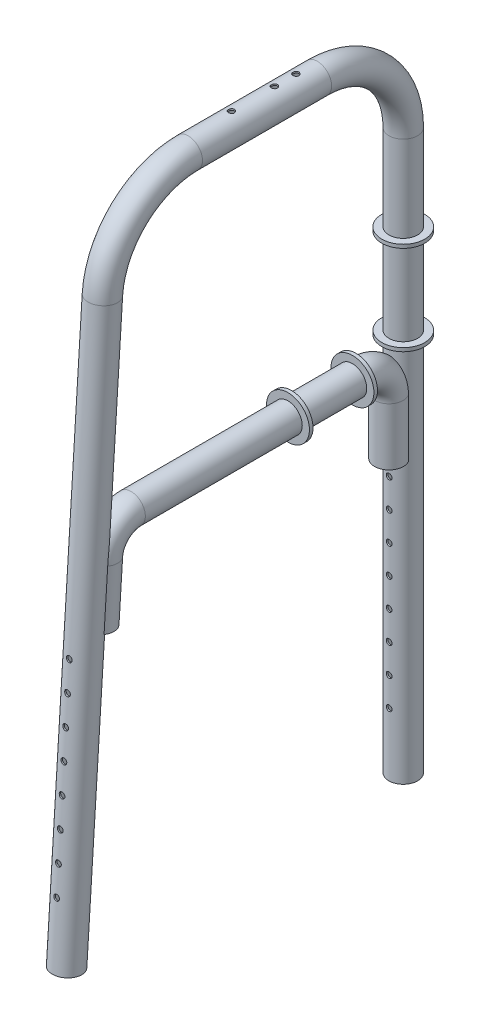
from build123d import *

# Parameters (mm, degrees)
SKETCH40_R           = 19.99999999999999
SKETCH40_R_2         = 17.99999999999999
SKETCH45_R           = 20
SKETCH45_R_2         = 18.000000000000004
CUT_SWEEP1_PROFILE_R = 20
CUT_EXTRUDE1_REACH   = 957.457
SKETCH22_R           = 4.000000000000002
SKETCH59_W           = 10
SKETCH59_H           = 5
SKETCH66_W           = 5
SKETCH66_H           = 10
SKETCH71_R           = 4.200000000000001
SKETCH71_R_2         = 4.2
SKETCH71_R_3         = 4.199999999999999
CUT_EXTRUDE3_DEPTH   = 40
SKETCH73_R           = 4.000000000000001
CUT_EXTRUDE4_DEPTH   = 1026.5520028632297


with BuildPart() as part:
    # Sweep2: sweep along a path in Sketch1
    with BuildLine(Plane(origin=(0, 0, 0), x_dir=(0, 0, -1), z_dir=(1, 0, 0))) as sweep2_path:
        Line((-237.13540242038945, 0), (-187.13540242038937, 787.6027487983755))
        ThreePointArc((-187.13540242038937, 787.6027487983755), (-149.49734187871428, 867.4995138723783), (-67.3764853799084, 900))
        Line((-67.3764853799084, 900), (112.86459757961059, 900))
        ThreePointArc((112.86459757961059, 900), (197.71741132199628, 864.8528137423857), (232.86459757961057, 780))
        Line((232.86459757961057, 780), (232.86459757961057, 0))
    # Sketch40 → Sweep2 (sweep)
    with BuildSketch(Plane(origin=(0, 0, 237.13540242038948), x_dir=(1, 0, 0), z_dir=(0, 0.9979909753373415, -0.06335623998646216))):
        Circle(SKETCH40_R)
        Circle(SKETCH40_R_2, mode=Mode.SUBTRACT)
    sweep(path=sweep2_path.line)


with BuildPart() as body_2:
    # Sweep3: sweep along a path in Sketch15
    with BuildLine(Plane(origin=(0, 0, 0), x_dir=(0, 0, -1), z_dir=(1, 0, 0))) as sweep3_path:
        Line((-192.17558291364261, 392.53424959945824), (-187.09688047627466, 472.5342495994585))
        ThreePointArc((-187.09688047627466, 472.5342495994585), (-174.55086029571626, 499.1665046241261), (-147.17724146278098, 510))
        Line((-147.17724146278098, 510), (172.86459757961066, 510.0000000000001))
        ThreePointArc((172.86459757961066, 510.0000000000001), (201.14886882707256, 498.28427124746196), (212.86459757961066, 470.00000000000006))
        Line((212.86459757961066, 470.00000000000006), (212.86459757961066, 390))
    # Sketch45 → Sweep3 (sweep)
    with BuildSketch(Plane(origin=(0, 392.5342495994583, 192.17558291364267), x_dir=(1, 0, 0), z_dir=(0, 0.9979909753373414, -0.06335623998646218))):
        Circle(SKETCH45_R)
        Circle(SKETCH45_R_2, mode=Mode.SUBTRACT)
    sweep(path=sweep3_path.line)

    # Cut-Sweep1: sweep along a path in Sketch1_3
    with BuildLine(Plane(origin=(0, 0, 0), x_dir=(0, 0, -1), z_dir=(1, 0, 0))) as cut_sweep1_path:
        Line((-237.13540242038945, 0), (-187.13540242038937, 787.6027487983755))
        ThreePointArc((-187.13540242038937, 787.6027487983755), (-149.49734187871428, 867.4995138723783), (-67.3764853799084, 900))
        Line((-67.3764853799084, 900), (112.86459757961059, 900))
        ThreePointArc((112.86459757961059, 900), (197.71741132199628, 864.8528137423857), (232.86459757961057, 780))
        Line((232.86459757961057, 780), (232.86459757961057, 0))
    # Cut-Sweep1 profile (on start of the path) → Cut-Sweep1 (sweep, cut)
    with BuildSketch(Plane(origin=(0, 0, 237.13540242038945), x_dir=(0, 0.06335623998646217, 0.9979909753373414), z_dir=(0, 0.9979909753373414, -0.06335623998646217))):
        Circle(CUT_SWEEP1_PROFILE_R)
    sweep(path=cut_sweep1_path.line, mode=Mode.SUBTRACT)


with BuildPart() as part_1:
    add(part.part)

    # Combine1: union body 2
    add(body_2.part)

    # Sketch22 → Cut-Extrude1 (cut, up to next)
    with BuildSketch(Plane.XY, mode=Mode.PRIVATE) as cut_extrude1_sk1:
        with Locations((-2.9157e-12, 367.9999999999999)):
            Circle(SKETCH22_R)
    cut_extrude1_tool1 = extrude(cut_extrude1_sk1.sketch, amount=-CUT_EXTRUDE1_REACH, mode=Mode.PRIVATE) & part_1.part
    # Sketch22 → Cut-Extrude1 (cut, up to next)
    with BuildSketch(Plane.XY, mode=Mode.PRIVATE) as cut_extrude1_sk2:
        with Locations((-2.49917e-12, 327.9999999999999)):
            Circle(SKETCH22_R)
    cut_extrude1_tool2 = extrude(cut_extrude1_sk2.sketch, amount=-CUT_EXTRUDE1_REACH, mode=Mode.PRIVATE) & part_1.part
    # Sketch22 → Cut-Extrude1 (cut, up to next)
    with BuildSketch(Plane.XY, mode=Mode.PRIVATE) as cut_extrude1_sk3:
        with Locations((-2.08264e-12, 287.99999999999994)):
            Circle(SKETCH22_R)
    cut_extrude1_tool3 = extrude(cut_extrude1_sk3.sketch, amount=-CUT_EXTRUDE1_REACH, mode=Mode.PRIVATE) & part_1.part
    # Sketch22 → Cut-Extrude1 (cut, up to next)
    with BuildSketch(Plane.XY, mode=Mode.PRIVATE) as cut_extrude1_sk4:
        with Locations((-1.66611e-12, 247.99999999999994)):
            Circle(SKETCH22_R)
    cut_extrude1_tool4 = extrude(cut_extrude1_sk4.sketch, amount=-CUT_EXTRUDE1_REACH, mode=Mode.PRIVATE) & part_1.part
    # Sketch22 → Cut-Extrude1 (cut, up to next)
    with BuildSketch(Plane.XY, mode=Mode.PRIVATE) as cut_extrude1_sk5:
        with Locations((-1.24959e-12, 207.99999999999997)):
            Circle(SKETCH22_R)
    cut_extrude1_tool5 = extrude(cut_extrude1_sk5.sketch, amount=-CUT_EXTRUDE1_REACH, mode=Mode.PRIVATE) & part_1.part
    # Sketch22 → Cut-Extrude1 (cut, up to next)
    with BuildSketch(Plane.XY, mode=Mode.PRIVATE) as cut_extrude1_sk6:
        with Locations((-8.3306e-13, 167.99999999999997)):
            Circle(SKETCH22_R)
    cut_extrude1_tool6 = extrude(cut_extrude1_sk6.sketch, amount=-CUT_EXTRUDE1_REACH, mode=Mode.PRIVATE) & part_1.part
    # Sketch22 → Cut-Extrude1 (cut, up to next)
    with BuildSketch(Plane.XY, mode=Mode.PRIVATE) as cut_extrude1_sk7:
        with Locations((-4.1653e-13, 128)):
            Circle(SKETCH22_R)
    cut_extrude1_tool7 = extrude(cut_extrude1_sk7.sketch, amount=-CUT_EXTRUDE1_REACH, mode=Mode.PRIVATE) & part_1.part
    # Sketch22 → Cut-Extrude1 (cut, up to next)
    with BuildSketch(Plane.XY, mode=Mode.PRIVATE) as cut_extrude1_sk8:
        with Locations((0, 88)):
            Circle(SKETCH22_R)
    cut_extrude1_tool8 = extrude(cut_extrude1_sk8.sketch, amount=-CUT_EXTRUDE1_REACH, mode=Mode.PRIVATE) & part_1.part
    add(cut_extrude1_tool1.solids().sort_by_distance((0, 368, 0))[0], mode=Mode.SUBTRACT)
    add(cut_extrude1_tool2.solids().sort_by_distance((0, 328, 0))[0], mode=Mode.SUBTRACT)
    add(cut_extrude1_tool3.solids().sort_by_distance((0, 288, 0))[0], mode=Mode.SUBTRACT)
    add(cut_extrude1_tool4.solids().sort_by_distance((0, 248, 0))[0], mode=Mode.SUBTRACT)
    add(cut_extrude1_tool5.solids().sort_by_distance((0, 208, 0))[0], mode=Mode.SUBTRACT)
    add(cut_extrude1_tool6.solids().sort_by_distance((0, 168, 0))[0], mode=Mode.SUBTRACT)
    add(cut_extrude1_tool7.solids().sort_by_distance((0, 128, 0))[0], mode=Mode.SUBTRACT)
    add(cut_extrude1_tool8.solids().sort_by_distance((0, 88, 0))[0], mode=Mode.SUBTRACT)

    # Sketch59 → Revolve1 (revolve)
    with BuildSketch(Plane(origin=(0, 0, 0), x_dir=(0, 0, -1), z_dir=(1, 0, 0))):
        Polygon((212.86459757961063, 655.0000000000001), (202.8645975796106, 655.0000000000001), (202.86459757961057, 660.0000000000001), (212.86459757961063, 660.0000000000001), align=None)
        with Locations((207.86459757961063, 532.5000000000001)):
            Rectangle(SKETCH59_W, SKETCH59_H)
    revolve(axis=Axis((0, 5.2e-15, -232.86459757961063), (0, 1, 0)))

    # Sketch66 → Revolve2 (revolve)
    with BuildSketch(Plane(origin=(0, 0, 0), x_dir=(0, 0, -1), z_dir=(1, 0, 0))):
        with Locations((164.36459757961063, 535.0000000000001)):
            Rectangle(SKETCH66_W, SKETCH66_H)
        with Locations((74.36459757961065, 535.0000000000001)):
            Rectangle(SKETCH66_W, SKETCH66_H)
    revolve(axis=Axis((0, 510.0000000000002, -172.86459757961066), (0, -3.5e-16, 1)))

    # Sketch71 → Cut-Extrude3 (cut)
    with BuildSketch(Plane(origin=(0, 920, 0), x_dir=(1, 0, 0), z_dir=(0, 1, 0))):
        with Locations((0, 52.86459757961058)):
            Circle(SKETCH71_R)
        with Locations((0, -7.135402420389417)):
            Circle(SKETCH71_R_2)
        with Locations((0, 82.86459757961057)):
            Circle(SKETCH71_R_3)
    extrude(amount=-CUT_EXTRUDE3_DEPTH, mode=Mode.SUBTRACT)

    # Sketch73 → Cut-Extrude4 (cut, through all)
    with BuildSketch(Plane(origin=(0, 13.726699063774017, 216.22371829112973), x_dir=(-1, 0, 0), z_dir=(0, -0.06335623998646216, -0.9979909753373414))):
        with Locations((0, 74.97599253496752)):
            Circle(SKETCH73_R)
        with Locations((-1.3878e-13, 114.97599253496752)):
            Circle(SKETCH73_R)
        with Locations((-2.7756e-13, 154.97599253496753)):
            Circle(SKETCH73_R)
        with Locations((-4.1633e-13, 194.9759925349675)):
            Circle(SKETCH73_R)
        with Locations((-5.5511e-13, 234.97599253496753)):
            Circle(SKETCH73_R)
        with Locations((-6.8001e-13, 274.97599253496753)):
            Circle(SKETCH73_R)
        with Locations((-8.1879e-13, 314.9759925349675)):
            Circle(SKETCH73_R)
        with Locations((-9.5757e-13, 354.97599253496753)):
            Circle(SKETCH73_R)
    extrude(amount=-CUT_EXTRUDE4_DEPTH, mode=Mode.SUBTRACT)


solid = part_1.part
